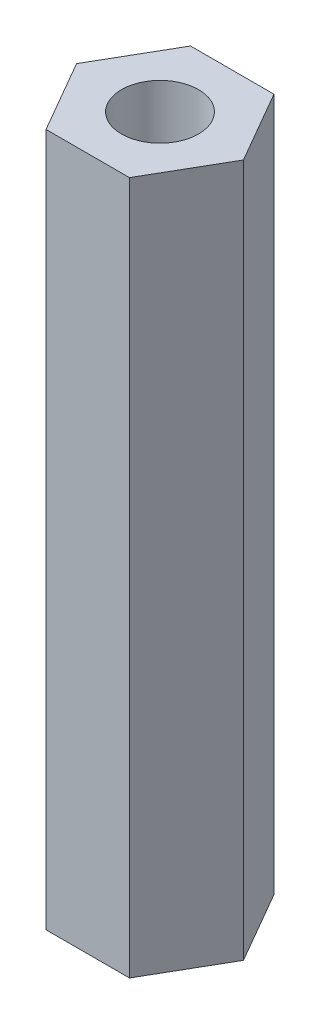
from build123d import *

# Parameters (mm, degrees)
SKETCH1_R           = 1.5
BOSS_EXTRUDE1_DEPTH = 27


with BuildPart() as part:
    # Sketch1 → Boss-Extrude1 (new body)
    with BuildSketch(Plane(origin=(0, 0, 0), x_dir=(1, 0, 0), z_dir=(0, 1, 0))):
        Polygon((3.25, 0), (1.625, 2.814582562), (-1.625, 2.814582562), (-3.25, 0), (-1.625, -2.814582562), (1.625, -2.814582562), align=None)
        Circle(SKETCH1_R, mode=Mode.SUBTRACT)
    extrude(amount=BOSS_EXTRUDE1_DEPTH)


solid = part.part
